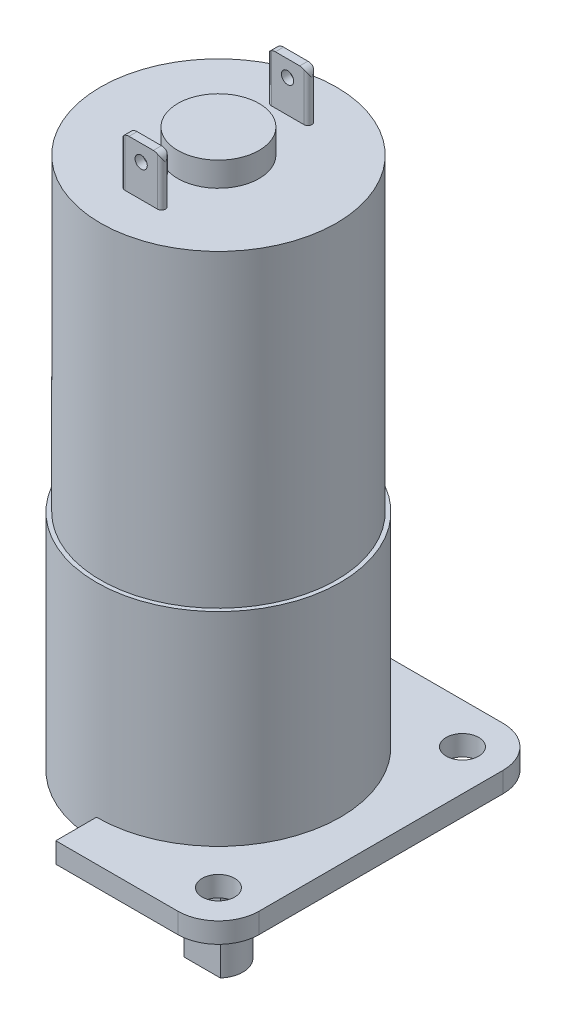
from build123d import *

# Parameters (mm, degrees)
CROQUIS1_R               = 14.5
MOTOR_DEPTH              = 38
CROQUIS2_R               = 5
SALIENTE_POSTERIOR_DEPTH = 3
BORNES_DEPTH             = 6
CROQUIS4_R               = 0.75
AGUJERO_BORNES_DEPTH     = 25
CROQUIS5_R               = 15
CAJA_REDUCTORA_DEPTH     = 25
CROQUIS6_R               = 2
BRIDA_DEPTH              = 2.5
CROQUIS7_R               = 6.5
SALIENTE_EJE_DEPTH       = 3
CROQUIS8_R               = 3
EJE_DEPTH                = 17
CORTE_PLANO_EJE_DEPTH    = 10
CROQUIS10_R              = 2
CORTE_BRIDA_DEPTH        = 10


with BuildPart() as part:
    # Croquis1 → Motor (new body)
    with BuildSketch(Plane(origin=(0, 0, 0), x_dir=(1, 0, 0), z_dir=(0, 1, 0))):
        Circle(CROQUIS1_R)
    extrude(amount=MOTOR_DEPTH)

    # Croquis2 → Saliente posterior (add)
    with BuildSketch(Plane(origin=(0, 38, 0), x_dir=(1, 0, 0), z_dir=(0, 1, 0))):
        Circle(CROQUIS2_R)
    extrude(amount=SALIENTE_POSTERIOR_DEPTH)

    # Croquis3 → Bornes (add)
    with BuildSketch(Plane(origin=(0, 38, 0), x_dir=(1, 0, 0), z_dir=(0, 1, 0))):
        with BuildLine():
            Line((-2, 9.5), (2, 9.5))
            ThreePointArc((2, 9.5), (2.5, 9), (2, 8.5))
            Line((2, 8.5), (-2, 8.5))
            ThreePointArc((-2, 8.5), (-2.5, 9), (-2, 9.5))
        make_face()
        with BuildLine():
            Line((-2, -9.5), (2, -9.5))
            ThreePointArc((2, -9.5), (2.5, -9), (2, -8.5))
            Line((2, -8.5), (-2, -8.5))
            ThreePointArc((-2, -8.5), (-2.5, -9), (-2, -9.5))
        make_face()
    extrude(amount=BORNES_DEPTH)

    # Croquis4 → Agujero Bornes (cut, through all)
    with BuildSketch(Plane.XY.offset(9.5)):
        with Locations((0, 42)):
            Circle(CROQUIS4_R)
        with BuildLine():
            ThreePointArc((2, 43.866025404), (2.366025404, 43.5), (2.5, 43))
            Line((2.5, 43), (2.5, 44))
            Line((2.5, 44), (2, 44))
            Line((2, 44), (2, 43.866025404))
        make_face()
        with BuildLine():
            ThreePointArc((1.5, 44), (1.758819045, 43.965925826), (2, 43.866025404))
            Line((2, 43.866025404), (2, 44))
            Line((2, 44), (1.5, 44))
        make_face()
        with BuildLine():
            Line((-2, 43.866025404), (-2, 44))
            Line((-2, 44), (-2.5, 44))
            Line((-2.5, 44), (-2.5, 43))
            ThreePointArc((-2.5, 43), (-2.366025404, 43.5), (-2, 43.866025404))
        make_face()
        with BuildLine():
            ThreePointArc((-2, 43.866025404), (-1.758819045, 43.965925826), (-1.5, 44))
            Line((-1.5, 44), (-2, 44))
            Line((-2, 44), (-2, 43.866025404))
        make_face()
    extrude(amount=-AGUJERO_BORNES_DEPTH, mode=Mode.SUBTRACT)

    # Croquis5 → Caja reductora (add)
    with BuildSketch(Plane.XZ):
        Circle(CROQUIS5_R)
    extrude(amount=CAJA_REDUCTORA_DEPTH)

    # Croquis6 → Brida (add)
    with BuildSketch(Plane.XZ.offset(25)):
        with BuildLine():
            Line((-15, 20), (15, 20))
            ThreePointArc((15, 20), (18.535533906, 18.535533906), (20, 15))
            Line((20, 15), (20, -15))
            ThreePointArc((20, -15), (18.535533906, -18.535533906), (15, -20))
            Line((15, -20), (-15, -20))
            ThreePointArc((-15, -20), (-18.535533906, -18.535533906), (-20, -15))
            Line((-20, -15), (-20, 15))
            ThreePointArc((-20, 15), (-18.535533906, 18.535533906), (-15, 20))
        make_face()
        with Locations((-15, 15)):
            Circle(CROQUIS6_R, mode=Mode.SUBTRACT)
        with Locations((15, 15)):
            Circle(CROQUIS6_R, mode=Mode.SUBTRACT)
        with Locations((15, -15)):
            Circle(CROQUIS6_R, mode=Mode.SUBTRACT)
        with Locations((-15, -15)):
            Circle(CROQUIS6_R, mode=Mode.SUBTRACT)
    extrude(amount=BRIDA_DEPTH)

    # Croquis7 → Saliente eje (add)
    with BuildSketch(Plane.XZ.offset(27.5)):
        Circle(CROQUIS7_R)
    extrude(amount=SALIENTE_EJE_DEPTH)

    # Croquis8 → Eje (add)
    with BuildSketch(Plane.XZ.offset(30.5)):
        Circle(CROQUIS8_R)
    extrude(amount=EJE_DEPTH)

    # Croquis9 → Corte Plano eje (cut)
    with BuildSketch(Plane.XZ.offset(47.5)):
        Polygon((-74.796206056, 2), (-2.236067977, 2), (2.236067977, 2), (74.796206056, 2), (74.796206056, 147.120276157), (-74.796206056, 147.120276157), align=None)
    extrude(amount=-CORTE_PLANO_EJE_DEPTH, mode=Mode.SUBTRACT)

    # Croquis10 → Corte Brida (cut)
    with BuildSketch(Plane(origin=(0, -25, 0), x_dir=(1, 0, 0), z_dir=(0, 1, 0))):
        with BuildLine():
            Line((0, 15), (0, 20))
            Line((0, 20), (-15, 20))
            ThreePointArc((-15, 20), (-18.535533906, 18.535533906), (-20, 15))
            Line((-20, 15), (-20, -15))
            ThreePointArc((-20, -15), (-18.535533906, -18.535533906), (-15, -20))
            Line((-15, -20), (0, -20))
            Line((0, -20), (0, -15))
            ThreePointArc((0, -15), (-15, 0), (0, 15))
        make_face()
        with Locations((-15, -15)):
            Circle(CROQUIS10_R, mode=Mode.SUBTRACT)
        with Locations((-15, 15)):
            Circle(CROQUIS10_R, mode=Mode.SUBTRACT)
    extrude(amount=-CORTE_BRIDA_DEPTH, mode=Mode.SUBTRACT)


solid = part.part
